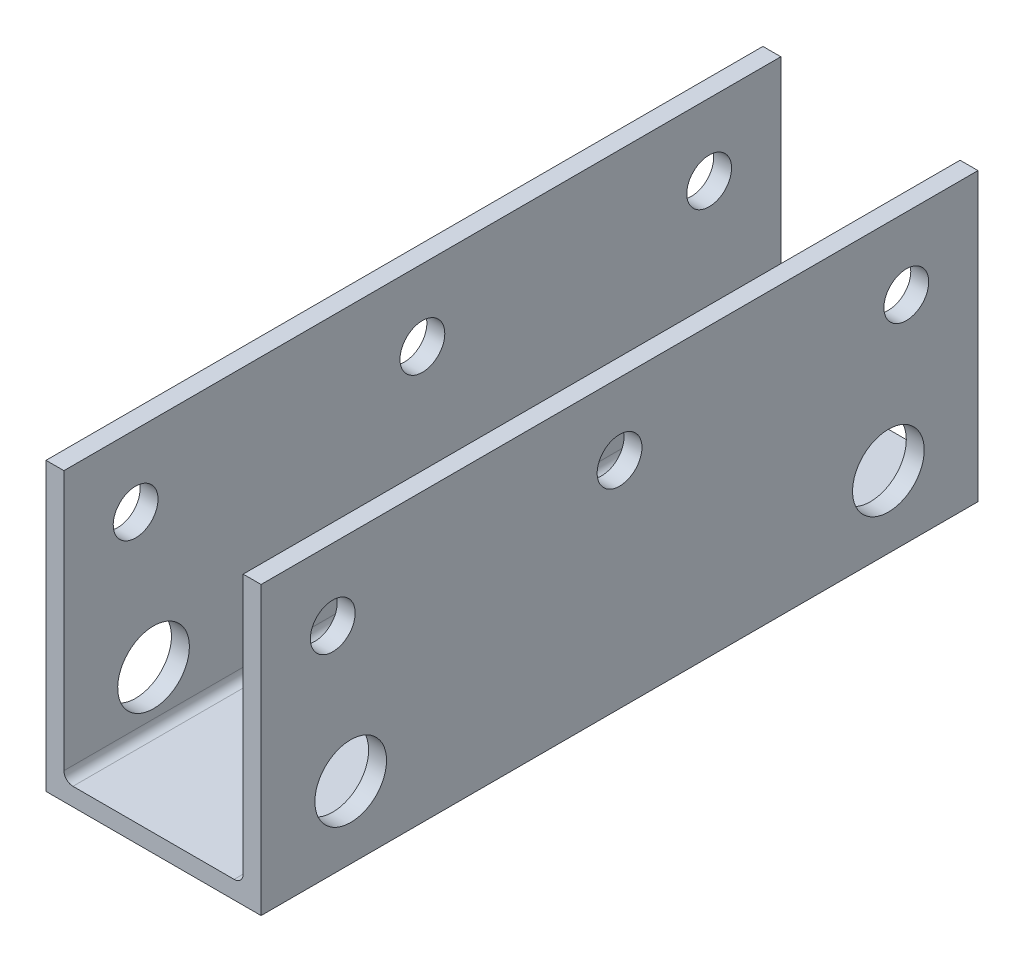
from build123d import *

# Parameters (mm, degrees)
BOSS_EXTRUDE1_DEPTH = 127
SKETCH2_R           = 6.35
SKETCH2_R_2         = 3.96875
CUT_EXTRUDE1_DEPTH  = 152.4
FILLET1_R           = 1.6002


with BuildPart() as part:
    # Sketch1 → Boss-Extrude1 (new body)
    with BuildSketch(Plane.XY):
        Polygon((3.175, 50.8), (3.175, 3.175), (34.925, 3.175), (34.925, 50.8), (38.1, 50.8), (38.1, 0), (0, 0), (0, 50.8), align=None)
    extrude(amount=BOSS_EXTRUDE1_DEPTH)

    # Sketch2 → Cut-Extrude1 (cut)
    with BuildSketch(Plane(origin=(38.1, 0, 0), x_dir=(0, 0, -1), z_dir=(1, 0, 0))):
        with Locations((-15.875, 12.7)):
            Circle(SKETCH2_R)
        with Locations((-111.125, 12.7)):
            Circle(SKETCH2_R)
        with Locations((-114.3, 38.1)):
            Circle(SKETCH2_R_2)
        with Locations((-63.5, 38.1)):
            Circle(SKETCH2_R_2)
        with Locations((-12.7, 38.1)):
            Circle(SKETCH2_R_2)
    extrude(amount=-CUT_EXTRUDE1_DEPTH, mode=Mode.SUBTRACT)

    # Fillet1
    fillet1_edges = [part.edges().sort_by_distance(p)[0] for p in [
        (3.175, 3.175, 63.5),
        (34.925, 3.175, 63.5),
    ]]
    fillet(fillet1_edges, radius=FILLET1_R)


solid = part.part
